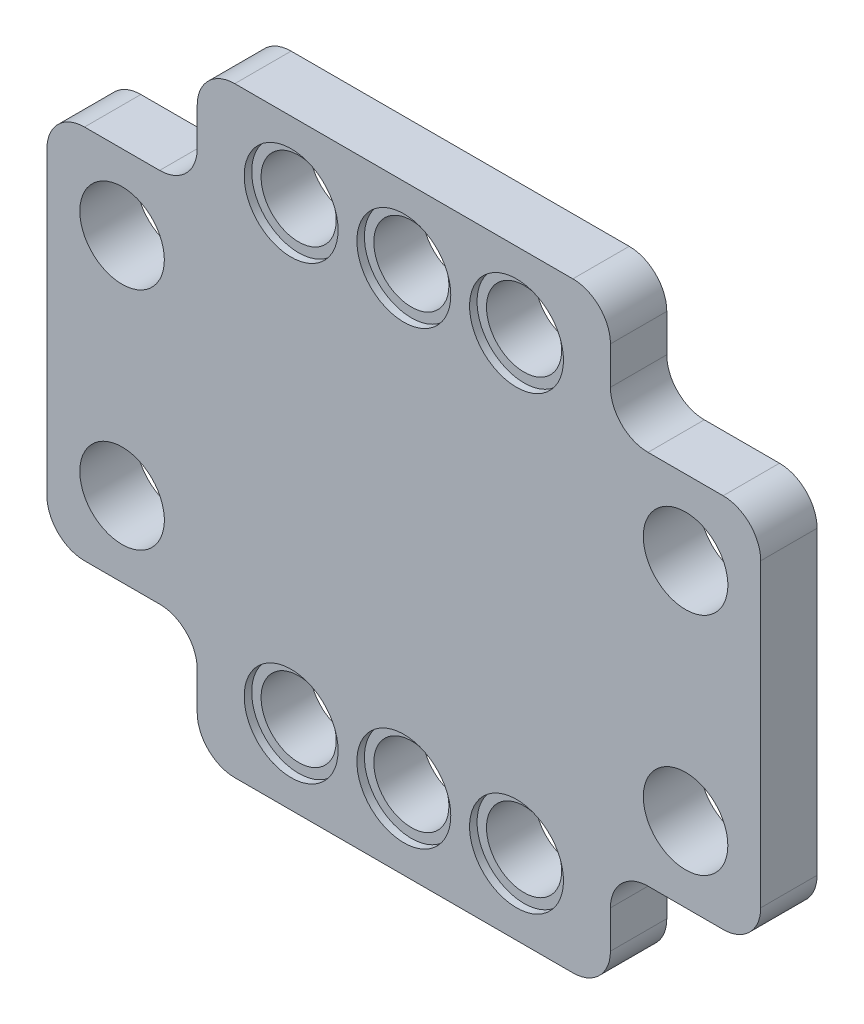
from build123d import *

# Parameters (mm, degrees)
ESQUISSE2_W                  = 38
ESQUISSE2_H                  = 32
BOSS_EXTRU_1_DEPTH           = 3
ESQUISSE3_R                  = 2
ESQUISSE3_R_2                = 2.25
ENL_V_MAT_EXTRU_1_DEPTH      = 1
ENL_V_MAT_EXTRU_1_DEPTH_BACK = 4
ESQUISSE4_R                  = 2.5
ENL_V_MAT_EXTRU_2_DEPTH      = 0.4
ESQUISSE5_W                  = 8
ESQUISSE5_H                  = 6
ENL_V_MAT_EXTRU_3_DEPTH      = 1
ENL_V_MAT_EXTRU_3_DEPTH_BACK = 4
CONG_1_R                     = 2


with BuildPart() as part:
    # Esquisse2 → Boss.-Extru.1 (new body)
    with BuildSketch(Plane.XY):
        with Locations((19, 16)):
            Rectangle(ESQUISSE2_W, ESQUISSE2_H)
    extrude(amount=BOSS_EXTRU_1_DEPTH)

    # Esquisse3 → Enlèv. mat.-Extru.1 (cut, two sides)
    with BuildSketch(Plane.XY.offset(3)) as enl_v_mat_extru_1_sk:
        with Locations((19, 28)):
            Circle(ESQUISSE3_R)
        with Locations((13, 28)):
            Circle(ESQUISSE3_R)
        with Locations((25, 28)):
            Circle(ESQUISSE3_R)
        with Locations((25, 4)):
            Circle(ESQUISSE3_R)
        with Locations((13, 4)):
            Circle(ESQUISSE3_R)
        with Locations((19, 4)):
            Circle(ESQUISSE3_R)
        with Locations((4, 22)):
            Circle(ESQUISSE3_R_2)
        with Locations((4, 10)):
            Circle(ESQUISSE3_R_2)
        with Locations((34, 10)):
            Circle(ESQUISSE3_R_2)
        with Locations((34, 22)):
            Circle(ESQUISSE3_R_2)
    extrude(amount=ENL_V_MAT_EXTRU_1_DEPTH, mode=Mode.SUBTRACT)
    extrude(enl_v_mat_extru_1_sk.sketch, amount=-ENL_V_MAT_EXTRU_1_DEPTH_BACK, mode=Mode.SUBTRACT)

    # Esquisse4 → Enlèv. mat.-Extru.2 (cut)
    with BuildSketch(Plane.XY.offset(3)):
        with Locations((13, 4)):
            Circle(ESQUISSE4_R)
        with Locations((19, 4)):
            Circle(ESQUISSE4_R)
        with Locations((25, 4)):
            Circle(ESQUISSE4_R)
        with Locations((25, 28)):
            Circle(ESQUISSE4_R)
        with Locations((19, 28)):
            Circle(ESQUISSE4_R)
        with Locations((13, 28)):
            Circle(ESQUISSE4_R)
    extrude(amount=-ENL_V_MAT_EXTRU_2_DEPTH, mode=Mode.SUBTRACT)

    # Esquisse5 → Enlèv. mat.-Extru.3 (cut, two sides)
    with BuildSketch(Plane.XY.offset(3)) as enl_v_mat_extru_3_sk:
        with Locations((4, 29)):
            Rectangle(ESQUISSE5_W, ESQUISSE5_H)
        with Locations((34, 29)):
            Rectangle(ESQUISSE5_W, ESQUISSE5_H)
        with Locations((34, 3)):
            Rectangle(ESQUISSE5_W, ESQUISSE5_H)
        with Locations((4, 3)):
            Rectangle(ESQUISSE5_W, ESQUISSE5_H)
    extrude(amount=ENL_V_MAT_EXTRU_3_DEPTH, mode=Mode.SUBTRACT)
    extrude(enl_v_mat_extru_3_sk.sketch, amount=-ENL_V_MAT_EXTRU_3_DEPTH_BACK, mode=Mode.SUBTRACT)

    # Congé1
    cong_1_edges = [part.edges().sort_by_distance(p)[0] for p in [
        (0, 26, 1.5),
        (8, 32, 1.5),
        (8, 26, 1.5),
        (30, 32, 1.5),
        (38, 26, 1.5),
        (30, 26, 1.5),
        (38, 6, 1.5),
        (30, 0, 1.5),
        (30, 6, 1.5),
        (8, 0, 1.5),
        (0, 6, 1.5),
        (8, 6, 1.5),
    ]]
    fillet(cong_1_edges, radius=CONG_1_R)


solid = part.part
